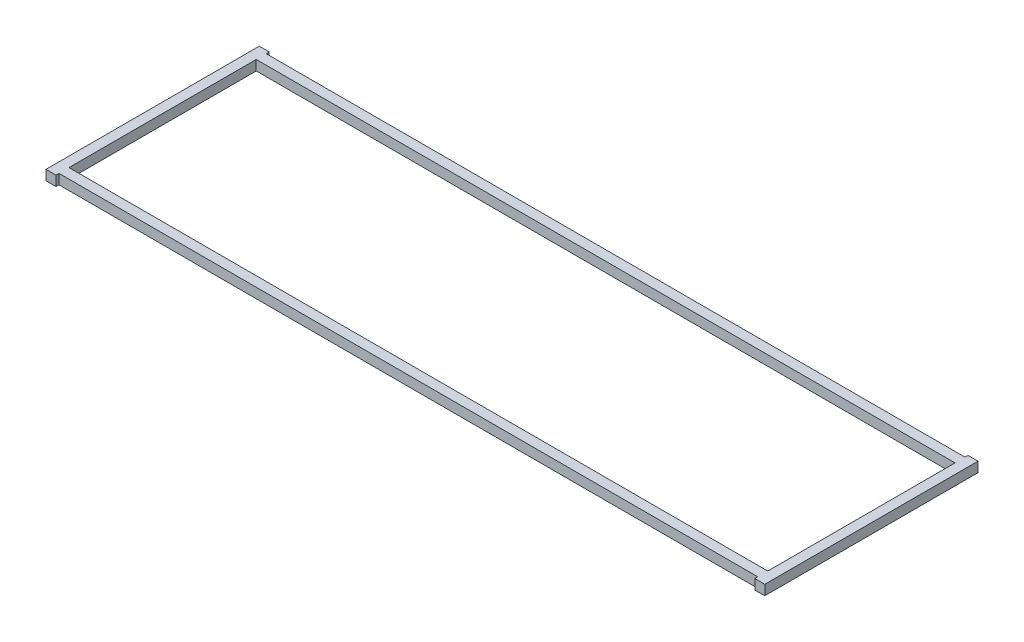
from build123d import *

# Parameters (mm, degrees)
SKETCH1_W           = 444.5
SKETCH1_H           = 119.126
BOSS_EXTRUDE1_DEPTH = 6.35


with BuildPart() as part:
    # Sketch1 → Boss-Extrude1 (new body)
    with BuildSketch(Plane(origin=(0, 0, 0), x_dir=(1, 0, 0), z_dir=(0, 1, 0))):
        Polygon((222.25, 67.821175), (228.6, 67.821175), (228.6, -67.821175), (222.25, -67.821175), (222.25, -65.913), (-222.25, -65.913), (-222.25, -67.821175), (-228.6, -67.821175), (-228.6, 67.821175), (-222.25, 67.821175), (-222.25, 65.913), (222.25, 65.913), align=None)
        Rectangle(SKETCH1_W, SKETCH1_H, mode=Mode.SUBTRACT)
    extrude(amount=BOSS_EXTRUDE1_DEPTH)


solid = part.part
